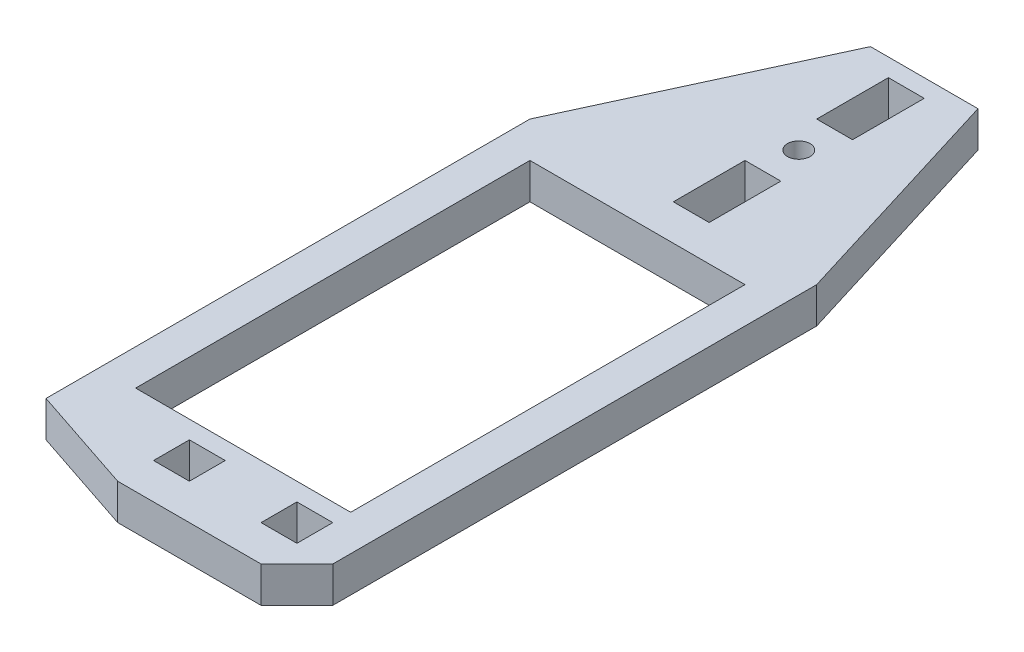
from build123d import *

# Parameters (mm, degrees)
SKETCH1_R           = 2
SKETCH1_W           = 6.35
SKETCH1_H           = 12.7
SKETCH1_H_2         = 6.35
SKETCH1_W_2         = 38.1
SKETCH1_H_3         = 69.85
BOSS_EXTRUDE1_DEPTH = 6.35


with BuildPart() as part:
    # Sketch1 → Boss-Extrude1 (new body)
    with BuildSketch(Plane(origin=(0, 0, 0), x_dir=(1, 0, 0), z_dir=(0, 1, 0))):
        Polygon((12.7, 117.475), (0, 89.958333333), (0, 76.2), (19.05, 76.2), (19.05, 88.9), (25.4, 88.9), (25.4, 76.2), (38.1, 76.2), (38.1, 96.8375), (31.75, 117.475), align=None)
        with Locations((22.225, 95.25)):
            Circle(SKETCH1_R, mode=Mode.SUBTRACT)
        with Locations((22.225, 107.95)):
            Rectangle(SKETCH1_W, SKETCH1_H, mode=Mode.SUBTRACT)
        Polygon((0, 76.2), (-6.35, 76.2), (-6.35, -9.525), (12.7, -15.875), (38.1, -15.875), (44.45, -9.525), (44.45, 76.2), (38.1, 76.2), (25.4, 76.2), (19.05, 76.2), align=None)
        with Locations((15.875, -6.35)):
            Rectangle(SKETCH1_W, SKETCH1_H_2, mode=Mode.SUBTRACT)
        with Locations((34.925, -6.35)):
            Rectangle(SKETCH1_W, SKETCH1_H_2, mode=Mode.SUBTRACT)
        with Locations((19.05, 34.925)):
            Rectangle(SKETCH1_W_2, SKETCH1_H_3, mode=Mode.SUBTRACT)
        Polygon((0, 89.958333333), (-6.35, 76.2), (0, 76.2), align=None)
        Polygon((44.45, 76.2), (38.1, 96.8375), (38.1, 76.2), align=None)
    extrude(amount=BOSS_EXTRUDE1_DEPTH)


solid = part.part
